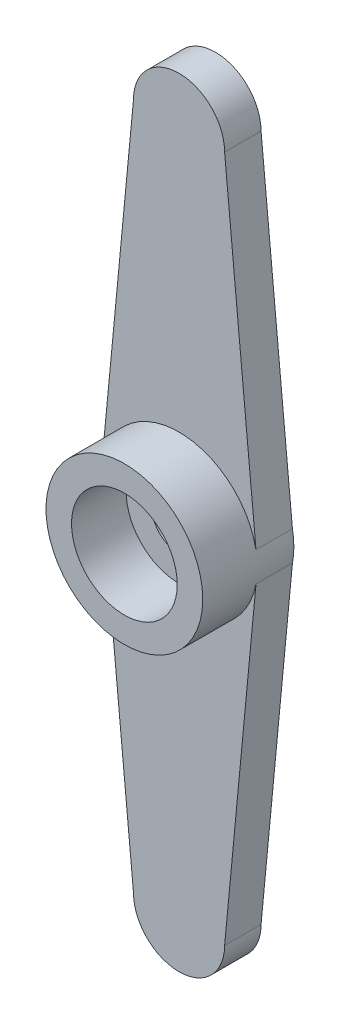
from build123d import *

# Parameters (mm, degrees)
BOSS_EXTRUDE1_DEPTH = 2
SKETCH2_R           = 4.3
SKETCH2_R_2         = 2.9
BOSS_EXTRUDE2_DEPTH = 3
SKETCH3_R           = 1.5
CUT_EXTRUDE1_DEPTH  = 3


with BuildPart() as part:
    # Sketch1 → Boss-Extrude1 (new body)
    with BuildSketch(Plane.XY):
        with BuildLine():
            Line((-2.5, 18.85), (-4.222289698, 0.813799547))
            ThreePointArc((-4.222289698, 0.813799547), (-4.3, 0), (-4.222289698, -0.813799547))
            Line((-4.222289698, -0.813799547), (-2.5, -18.85))
            ThreePointArc((-2.5, -18.85), (0, -21.35), (2.5, -18.85))
            Line((2.5, -18.85), (4.222289698, -0.813799547))
            ThreePointArc((4.222289698, -0.813799547), (4.3, 0), (4.222289698, 0.813799547))
            Line((4.222289698, 0.813799547), (2.5, 18.85))
            ThreePointArc((2.5, 18.85), (0, 21.35), (-2.5, 18.85))
        make_face()
    extrude(amount=BOSS_EXTRUDE1_DEPTH)

    # Sketch2 → Boss-Extrude2 (add)
    with BuildSketch(Plane.XY.offset(2)):
        Circle(SKETCH2_R)
        Circle(SKETCH2_R_2, mode=Mode.SUBTRACT)
    extrude(amount=BOSS_EXTRUDE2_DEPTH)

    # Sketch3 → Cut-Extrude1 (cut, through all)
    with BuildSketch(Plane.XY.offset(2)):
        Circle(SKETCH3_R)
    extrude(amount=-CUT_EXTRUDE1_DEPTH, mode=Mode.SUBTRACT)


solid = part.part
